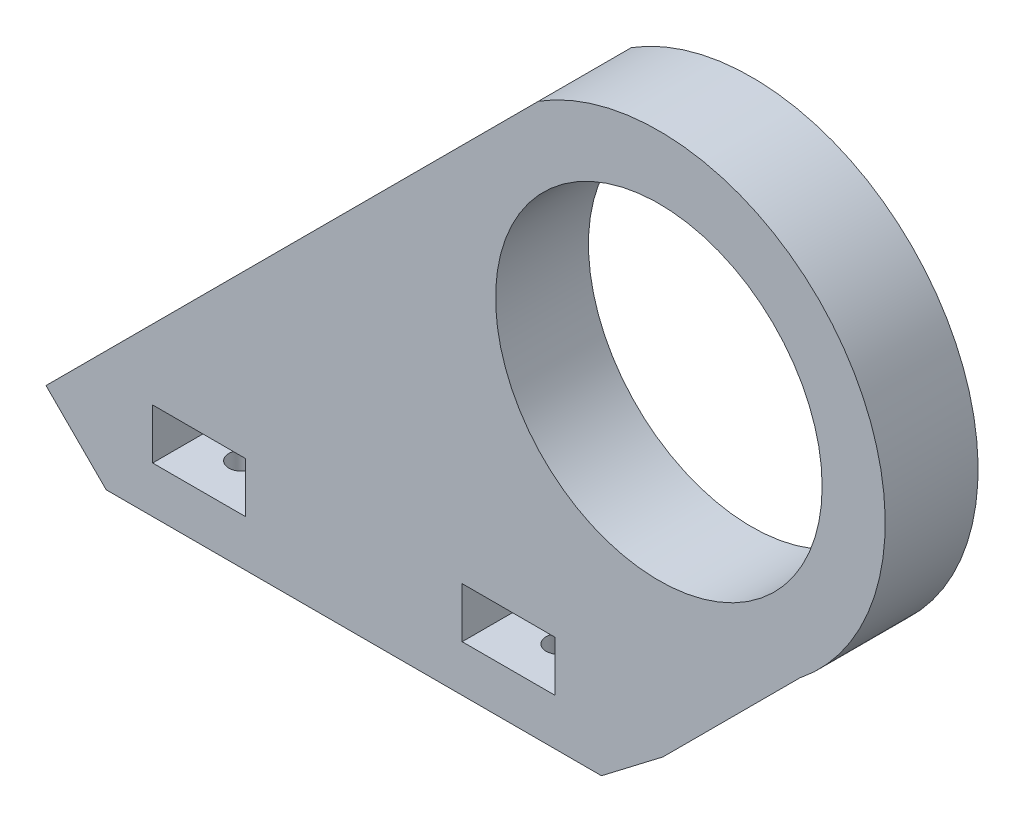
from build123d import *

# Parameters (mm, degrees)
BOSS_EXTRUDE2_DEPTH     = 12
SKETCH5_R               = 1.65
CUT_EXTRUDE3_DEPTH      = 6
SKETCH6_W               = 12
SKETCH6_H               = 6.5
CUT_EXTRUDE4_DEPTH      = 13
SKETCH8_W               = 64
SKETCH8_H               = 8
BOSS_EXTRUDE3_DEPTH     = 5
SKETCH11_R              = 1.65
CUT_EXTRUDE7_DEPTH      = 76.896039473
SKETCH13_R              = 21.1
CUT_EXTRUDE8_DEPTH      = 21
CUT_EXTRUDE9_DEPTH      = 71.896039473
CUT_EXTRUDE9_DEPTH_BACK = 10


with BuildPart() as part:
    # Sketch1 → Boss-Extrude2 (new body)
    with BuildSketch(Plane.XY):
        with BuildLine():
            Line((0, 0), (64, 0))
            Line((64, 0), (71.941945847, 6.076635266))
            Line((71.941945847, 6.076635266), (89.619615377, 23.754304796))
            ThreePointArc((89.619615377, 23.754304796), (95.283552654, 63.552389681), (55.861435714, 71.4177849))
            Line((55.861435714, 71.4177849), (-7.778174593, 7.778174593))
            Line((-7.778174593, 7.778174593), (0, 0))
        make_face()
    extrude(amount=BOSS_EXTRUDE2_DEPTH)

    # Sketch5 → Cut-Extrude3 (cut)
    with BuildSketch(Plane.XZ):
        with Locations((11.5, 6)):
            Circle(SKETCH5_R)
        with Locations((52.5, 6)):
            Circle(SKETCH5_R)
    extrude(amount=-CUT_EXTRUDE3_DEPTH, mode=Mode.SUBTRACT)

    # Sketch6 → Cut-Extrude4 (cut, through all)
    with BuildSketch(Plane.XY.offset(12)):
        with Locations((12, 9.25)):
            Rectangle(SKETCH6_W, SKETCH6_H)
        with Locations((52, 9.25)):
            Rectangle(SKETCH6_W, SKETCH6_H)
    extrude(amount=-CUT_EXTRUDE4_DEPTH, mode=Mode.SUBTRACT)

    # Sketch8 → Boss-Extrude3 (add)
    with BuildSketch(Plane.XZ):
        with Locations((32, -4)):
            Rectangle(SKETCH8_W, SKETCH8_H)
    extrude(amount=-BOSS_EXTRUDE3_DEPTH)

    # Sketch11 → Cut-Extrude7 (cut, through all)
    with BuildSketch(Plane.XZ):
        with Locations((11.5, -4)):
            Circle(SKETCH11_R)
        with Locations((52.5, -4)):
            Circle(SKETCH11_R)
    extrude(amount=-CUT_EXTRUDE7_DEPTH, mode=Mode.SUBTRACT)

    # Sketch13 → Cut-Extrude8 (cut, through all)
    with BuildSketch(Plane.XY.offset(12)):
        with Locations((71.414976798, 46.64721049)):
            Circle(SKETCH13_R)
    extrude(amount=-CUT_EXTRUDE8_DEPTH, mode=Mode.SUBTRACT)

    # Sketch15 → Cut-Extrude9 (cut, two sides)
    with BuildSketch(Plane(origin=(0, 5, 0), x_dir=(1, 0, 0), z_dir=(0, 1, 0))) as cut_extrude9_sk:
        with BuildLine():
            Line((45, 8), (19, 8))
            ThreePointArc((19, 8), (32, 2.615223689), (45, 8))
        make_face()
    extrude(amount=CUT_EXTRUDE9_DEPTH, mode=Mode.SUBTRACT)
    extrude(cut_extrude9_sk.sketch, amount=-CUT_EXTRUDE9_DEPTH_BACK, mode=Mode.SUBTRACT)


solid = part.part
